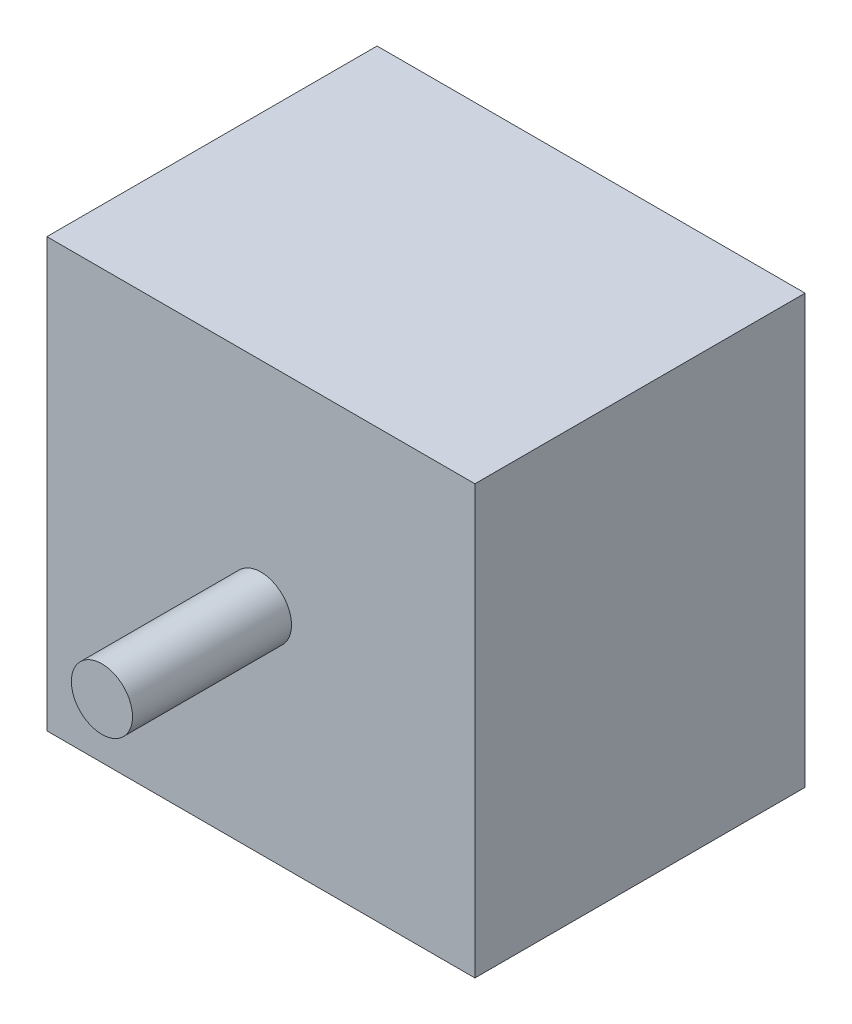
from build123d import *

# Parameters (mm, degrees)
SKETCH1_W           = 35
SKETCH1_H           = 35
BOSS_EXTRUDE1_DEPTH = 27
SKETCH1_3_R         = 2.5
BOSS_EXTRUDE2_DEPTH = 40


with BuildPart() as part:
    # Sketch1 → Boss-Extrude1 (new body)
    with BuildSketch(Plane.XY):
        with Locations((17.5, 17.5)):
            Rectangle(SKETCH1_W, SKETCH1_H)
    extrude(amount=BOSS_EXTRUDE1_DEPTH)

    # Sketch1_3 → Boss-Extrude2 (add)
    with BuildSketch(Plane.XY):
        with Locations((17.5, 17.5)):
            Circle(SKETCH1_3_R)
    extrude(amount=BOSS_EXTRUDE2_DEPTH)


solid = part.part
